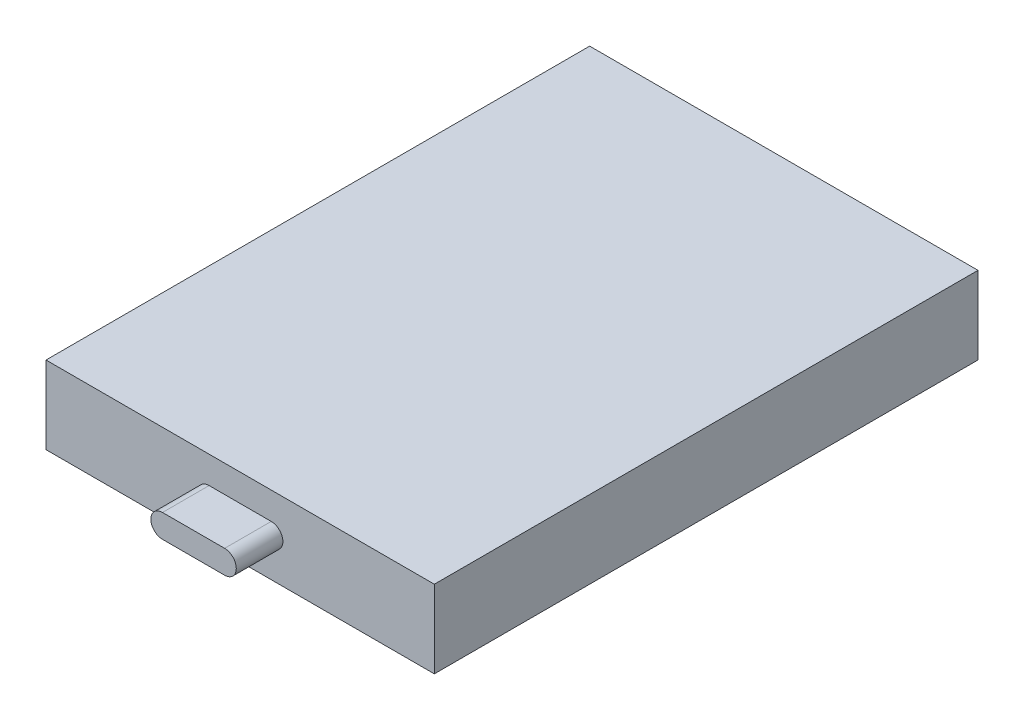
from build123d import *

# Parameters (mm, degrees)
SKETCH1_W           = 25
SKETCH1_H           = 5
BOSS_EXTRUDE1_DEPTH = 35
BOSS_EXTRUDE2_DEPTH = 3


with BuildPart() as part:
    # Sketch1 → Boss-Extrude1 (new body)
    with BuildSketch(Plane.XY):
        with Locations((12.5, -2.5)):
            Rectangle(SKETCH1_W, SKETCH1_H)
    extrude(amount=BOSS_EXTRUDE1_DEPTH)

    # Sketch2 → Boss-Extrude2 (add)
    with BuildSketch(Plane.XY.offset(35)):
        with BuildLine():
            Line((10.5, -1.75), (14.5, -1.75))
            ThreePointArc((14.5, -1.75), (15.25, -2.5), (14.5, -3.25))
            Line((14.5, -3.25), (10.5, -3.25))
            ThreePointArc((10.5, -3.25), (9.75, -2.5), (10.5, -1.75))
        make_face()
    extrude(amount=BOSS_EXTRUDE2_DEPTH)


solid = part.part
